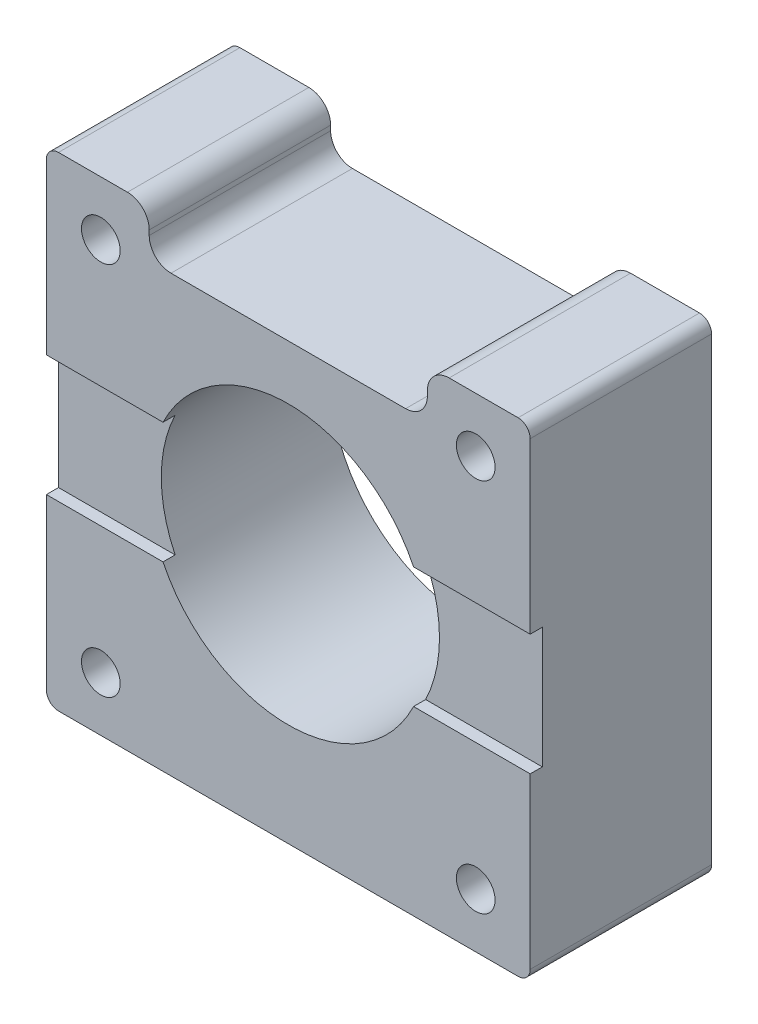
from build123d import *

# Parameters (mm, degrees)
SKETCH1_R           = 11.5
SKETCH1_R_2         = 1.6
BOSS_EXTRUDE1_DEPTH = 15
SKETCH2_W           = 40
SKETCH2_H           = 10
CUT_EXTRUDE1_DEPTH  = 1


with BuildPart() as part:
    # Sketch1 → Boss-Extrude1 (new body)
    with BuildSketch(Plane.XY):
        with BuildLine():
            Line((-20, 19), (-20, -19))
            ThreePointArc((-20, -19), (-19.707106781, -19.707106781), (-19, -20))
            Line((-19, -20), (19, -20))
            ThreePointArc((19, -20), (19.707106781, -19.707106781), (20, -19))
            Line((20, -19), (20, 19))
            ThreePointArc((20, 19), (19.707106781, 19.707106781), (19, 20))
            Line((19, 20), (13.3, 20))
            ThreePointArc((13.3, 20), (12.027207794, 19.472792206), (11.5, 18.2))
            Line((11.5, 18.2), (11.5, 17.8))
            ThreePointArc((11.5, 17.8), (10.972792206, 16.527207794), (9.7, 16))
            Line((9.7, 16), (-9.7, 16))
            ThreePointArc((-9.7, 16), (-10.972792206, 16.527207794), (-11.5, 17.8))
            Line((-11.5, 17.8), (-11.5, 18.2))
            ThreePointArc((-11.5, 18.2), (-12.027207794, 19.472792206), (-13.3, 20))
            Line((-13.3, 20), (-19, 20))
            ThreePointArc((-19, 20), (-19.707106781, 19.707106781), (-20, 19))
        make_face()
        Circle(SKETCH1_R, mode=Mode.SUBTRACT)
        with Locations((-15.5, 15.5)):
            Circle(SKETCH1_R_2, mode=Mode.SUBTRACT)
        with Locations((15.5, 15.5)):
            Circle(SKETCH1_R_2, mode=Mode.SUBTRACT)
        with Locations((15.5, -15.5)):
            Circle(SKETCH1_R_2, mode=Mode.SUBTRACT)
        with Locations((-15.5, -15.5)):
            Circle(SKETCH1_R_2, mode=Mode.SUBTRACT)
    extrude(amount=BOSS_EXTRUDE1_DEPTH)

    # Sketch2 → Cut-Extrude1 (cut)
    with BuildSketch(Plane.XY.offset(15)):
        Rectangle(SKETCH2_W, SKETCH2_H)
    extrude(amount=-CUT_EXTRUDE1_DEPTH, mode=Mode.SUBTRACT)


solid = part.part
